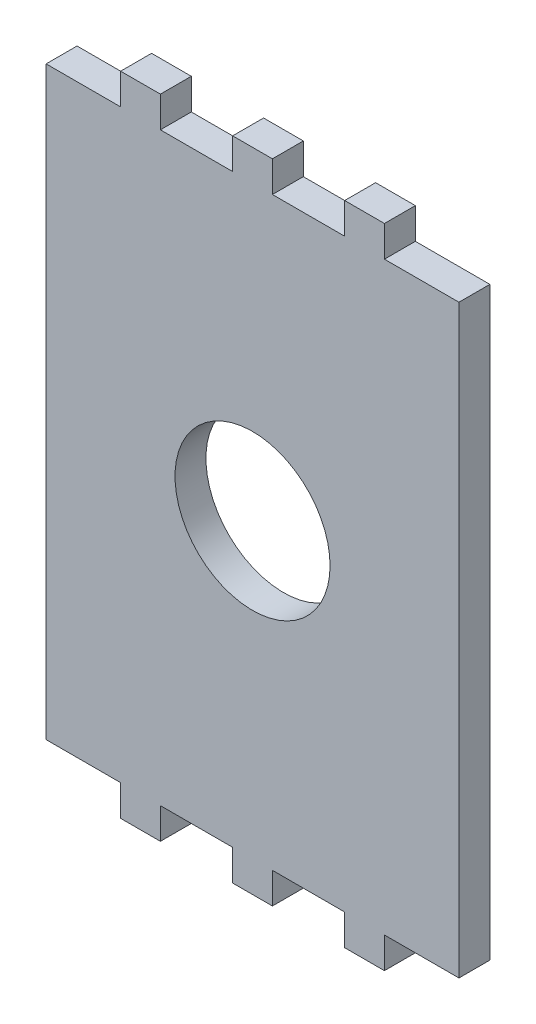
from build123d import *

# Parameters (mm, degrees)
SKETCH1_R           = 8
BOSS_EXTRUDE1_DEPTH = 3.175
SKETCH2_R           = 7.95936
BOSS_EXTRUDE3_DEPTH = 3.175


with BuildPart() as part:
    # Sketch1 → Boss-Extrude1 (new body)
    with BuildSketch(Plane.XY):
        Polygon((-13.5, 30), (-21.15, 30), (-21.15, -30), (-13.5, -30), (-13.5, -33.175), (-9.5, -33.175), (-9.5, -30), (-2, -30), (-2, -33.175), (2, -33.175), (2, -30), (9.5, -30), (9.5, -33.175), (13.5, -33.175), (13.5, -30), (21.15, -30), (21.15, 30), (13.5, 30), (13.5, 33.175), (9.5, 33.175), (9.5, 30), (2, 30), (2, 33.175), (-2, 33.175), (-2, 30), (-9.5, 30), (-9.5, 33.175), (-13.5, 33.175), align=None)
        Circle(SKETCH1_R, mode=Mode.SUBTRACT)
    extrude(amount=BOSS_EXTRUDE1_DEPTH)

    # Sketch2 → Boss-Extrude3 (add)
    with BuildSketch(Plane.XY.offset(3.175)):
        Polygon((21.19064, -30.04064), (21.19064, 30.04064), (13.54064, 30.04064), (13.54064, 33.21564), (9.45936, 33.21564), (9.45936, 30.04064), (2.04064, 30.04064), (2.04064, 33.21564), (-2.04064, 33.21564), (-2.04064, 30.04064), (-9.45936, 30.04064), (-9.45936, 33.21564), (-13.54064, 33.21564), (-13.54064, 30.04064), (-21.19064, 30.04064), (-21.19064, -30.04064), (-13.54064, -30.04064), (-13.54064, -33.21564), (-9.45936, -33.21564), (-9.45936, -30.04064), (-2.04064, -30.04064), (-2.04064, -33.21564), (2.04064, -33.21564), (2.04064, -30.04064), (9.45936, -30.04064), (9.45936, -33.21564), (13.54064, -33.21564), (13.54064, -30.04064), align=None)
        Circle(SKETCH2_R, mode=Mode.SUBTRACT)
    extrude(amount=-BOSS_EXTRUDE3_DEPTH)


solid = part.part
